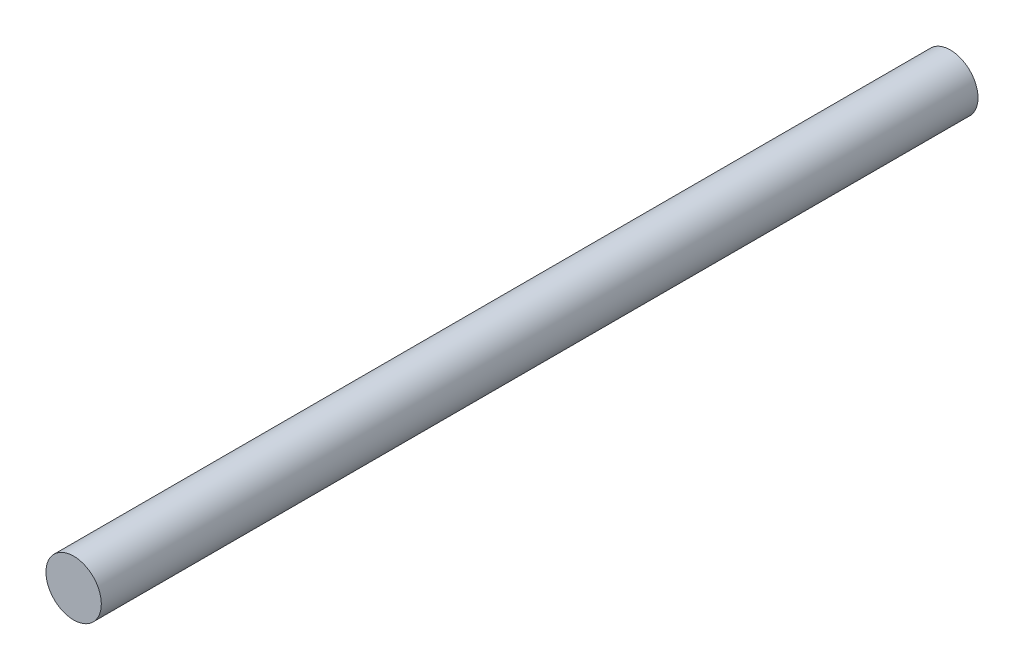
from build123d import *

# Parameters (mm, degrees)
SKETCH1_R           = 6
BOSS_EXTRUDE1_DEPTH = 190


with BuildPart() as part:
    # Sketch1 → Boss-Extrude1 (new body)
    with BuildSketch(Plane.XY):
        Circle(SKETCH1_R)
    extrude(amount=BOSS_EXTRUDE1_DEPTH)


solid = part.part
